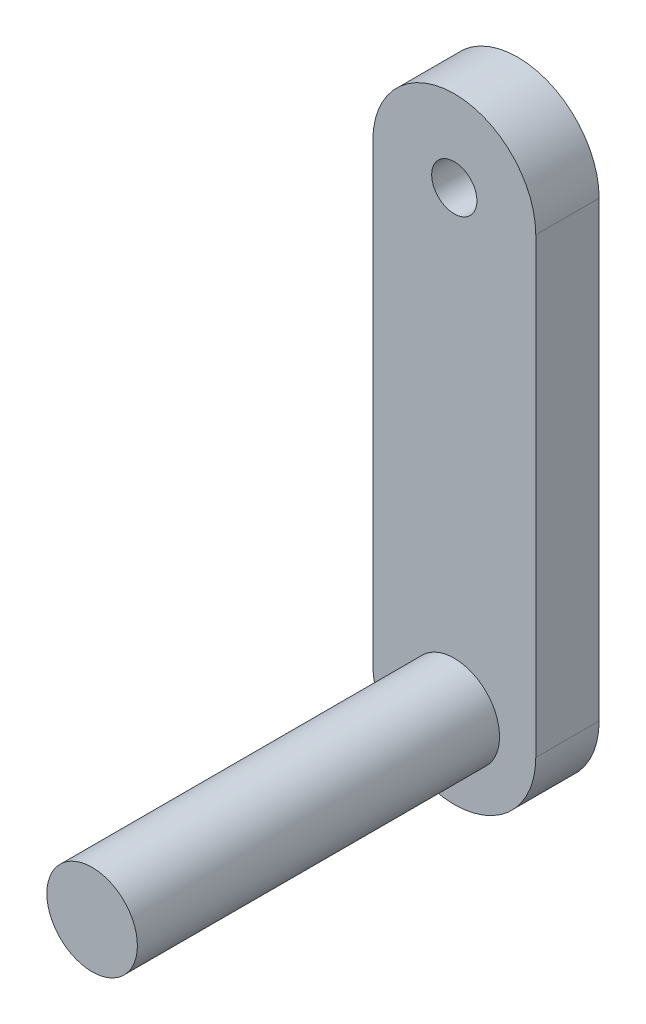
from build123d import *

# Parameters (mm, degrees)
BOSS_EXTRUDE1_DEPTH   = 7
SKETCH2_R             = 5
BOSS_EXTRUDE2_DEPTH   = 40
M6_TAPPED_HOLE1_D     = 5
M6_TAPPED_HOLE1_DEPTH = 15
M6_TAPPED_HOLE1_TIP   = 1.502151548


with BuildPart() as part:
    # Sketch1 → Boss-Extrude1 (new body)
    with BuildSketch(Plane.XY):
        with BuildLine():
            Line((-9, 50), (-9, 0))
            ThreePointArc((-9, 0), (0, -9), (9, 0))
            Line((9, 0), (9, 50))
            ThreePointArc((9, 50), (0, 59), (-9, 50))
        make_face()
    extrude(amount=BOSS_EXTRUDE1_DEPTH)

    # Sketch2 → Boss-Extrude2 (add)
    with BuildSketch(Plane.XY.offset(7)):
        with Locations(Location((0, 0, 0), (0, 0, 180))):  # turned: the seam where the file's is
            Circle(SKETCH2_R)
    extrude(amount=BOSS_EXTRUDE2_DEPTH)

    # M6 Tapped Hole1
    with Locations(Plane(origin=(0, 0, 0), x_dir=(-1, 0, 0), z_dir=(0, 0, -1))):
        with Locations((0, 50)):
            Hole(M6_TAPPED_HOLE1_D / 2, depth=M6_TAPPED_HOLE1_DEPTH)
            with Locations((0, 0, -(M6_TAPPED_HOLE1_DEPTH + M6_TAPPED_HOLE1_TIP / 2))):  # 118° drill point
                Cone(0, M6_TAPPED_HOLE1_D / 2, M6_TAPPED_HOLE1_TIP, mode=Mode.SUBTRACT)


solid = part.part
